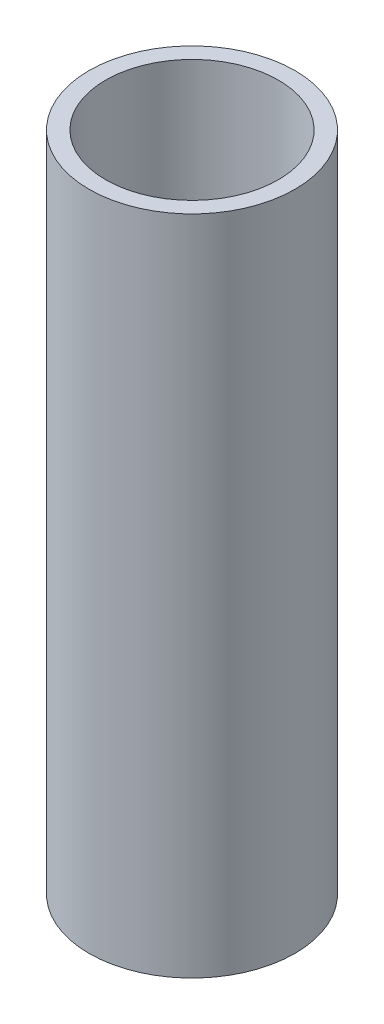
from build123d import *

# Parameters (mm, degrees)
SKETCH1_R           = 23.6982
BOSS_EXTRUDE1_DEPTH = 152.4
CUT_EXTRUDE1_REACH  = 154.4
SKETCH2_R           = 19.8882


with BuildPart() as part:
    # Sketch1 → Boss-Extrude1 (new body)
    with BuildSketch(Plane(origin=(0, 0, 0), x_dir=(1, 0, 0), z_dir=(0, 1, 0))):
        Circle(SKETCH1_R)
    extrude(amount=BOSS_EXTRUDE1_DEPTH)

    # Sketch2 → Cut-Extrude1 (cut, up to next)
    with BuildSketch(Plane(origin=(0, 152.4, 0), x_dir=(1, 0, 0), z_dir=(0, 1, 0)), mode=Mode.PRIVATE) as cut_extrude1_sk1:
        Circle(SKETCH2_R)
    cut_extrude1_tool1 = extrude(cut_extrude1_sk1.sketch, amount=-CUT_EXTRUDE1_REACH, mode=Mode.PRIVATE) & part.part
    add(cut_extrude1_tool1.solids().sort_by_distance((0, 152.4, 0))[0], mode=Mode.SUBTRACT)


solid = part.part
